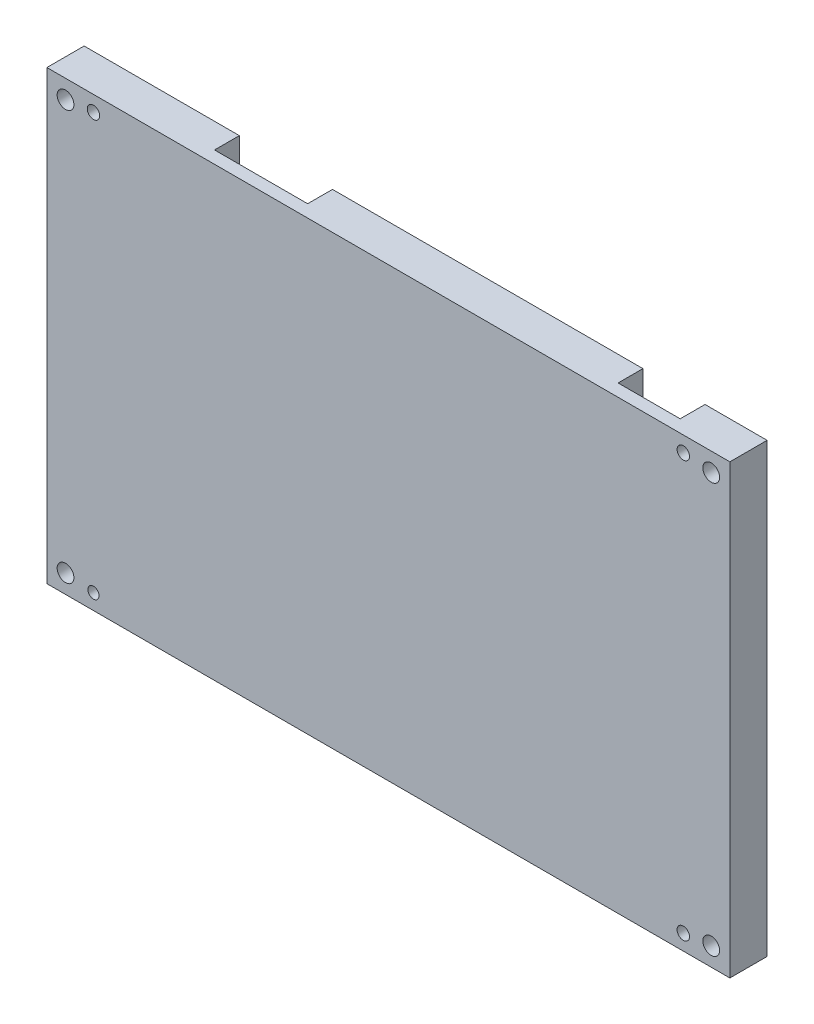
from build123d import *

# Parameters (mm, degrees)
MAIN_SKETCH_W        = 110
MAIN_SKETCH_H        = 72
MAIN_EXTRUSION_DEPTH = 6
MAIN_HOLE_SKETCH_R   = 1
MAIN_HOLE_SKETCH_R_2 = 0.9
MAIN_HOLE_DEPTH      = 7
EPIA_FIX_SKETCH_W    = 77
EPIA_FIX_SKETCH_H    = 40
EPIA_FIX_SKETCH_W_2  = 15
EPIA_FIX_SKETCH_H_2  = 8
EPIA_FIX_SKETCH_W_3  = 10
EPIA_FIX_SKETCH_W_4  = 8
EPIA_FIX_SKETCH_H_3  = 16
EPIA_FIX_DEPTH       = 4
FIX_SKETCH_R         = 1.35
FIX_HOLE_DEPTH       = 7


with BuildPart() as part:
    # Main-Sketch → Main-Extrusion (new body)
    with BuildSketch(Plane.XY):
        with Locations((55, 36)):
            Rectangle(MAIN_SKETCH_W, MAIN_SKETCH_H)
    extrude(amount=MAIN_EXTRUSION_DEPTH)

    # Main-Hole-Sketch → Main-Hole (cut, through all)
    with BuildSketch(Plane.XY.offset(6)):
        with Locations((7.5, 69.5)):
            Circle(MAIN_HOLE_SKETCH_R)
        with Locations((7.5, 2.5)):
            Circle(MAIN_HOLE_SKETCH_R_2)
        with Locations((102.5, 2.5)):
            Circle(MAIN_HOLE_SKETCH_R)
        with Locations((102.5, 69.5)):
            Circle(MAIN_HOLE_SKETCH_R)
    extrude(amount=-MAIN_HOLE_DEPTH, mode=Mode.SUBTRACT)

    # Epia-Fix-Sketch → Epia-Fix (cut)
    with BuildSketch(Plane.XY):
        with Locations((43.5, 27)):
            Rectangle(EPIA_FIX_SKETCH_W, EPIA_FIX_SKETCH_H)
        with Locations((32.5, 68)):
            Rectangle(EPIA_FIX_SKETCH_W_2, EPIA_FIX_SKETCH_H_2)
        with Locations((95, 68)):
            Rectangle(EPIA_FIX_SKETCH_W_3, EPIA_FIX_SKETCH_H_2)
        with Locations((98, 31)):
            Rectangle(EPIA_FIX_SKETCH_W_4, EPIA_FIX_SKETCH_H_3)
    extrude(amount=EPIA_FIX_DEPTH, mode=Mode.SUBTRACT)

    # Fix-Sketch → Fix-Hole (cut, through all)
    with BuildSketch(Plane.XY.offset(6)):
        with Locations((107, 69)):
            Circle(FIX_SKETCH_R)
        with Locations((107, 3)):
            Circle(FIX_SKETCH_R)
        with Locations((3, 69)):
            Circle(FIX_SKETCH_R)
        with Locations((3, 3)):
            Circle(FIX_SKETCH_R)
    extrude(amount=-FIX_HOLE_DEPTH, mode=Mode.SUBTRACT)


solid = part.part
